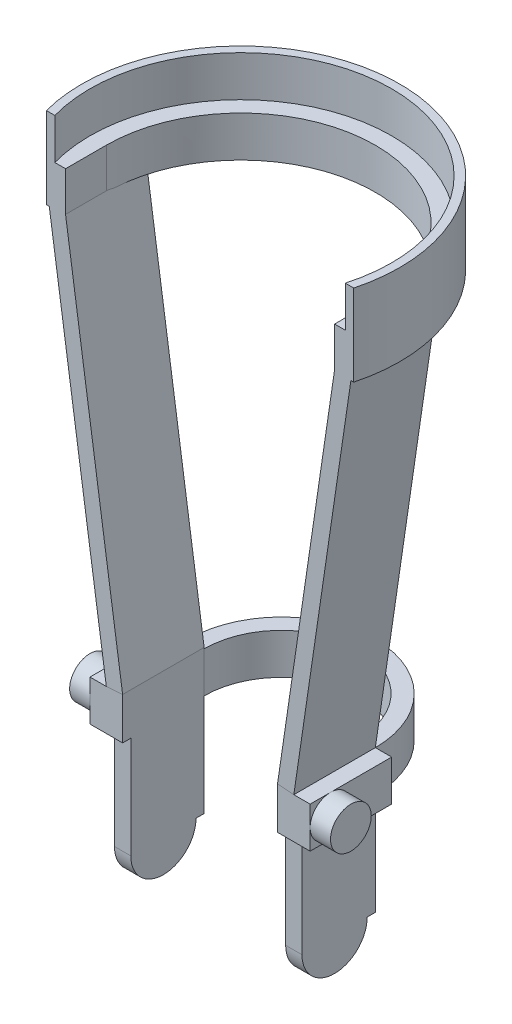
from build123d import *

# Parameters (mm, degrees)
EXTRUDE_4_DEPTH     = 10
EXTRUDE_8_DEPTH     = 20
SKETCH_16_W         = 8
SKETCH_16_H         = 40
SKETCH_19_W         = 8
SKETCH_19_H         = 40
SKETCH_21_R         = 16
EXTRUDE_13_DEPTH    = 8
SKETCH_22_R         = 16
EXTRUDE_14_DEPTH    = 8
SKETCH_23_W         = 7.590296008
SKETCH_23_H         = 50
CUT_EXTRUDE_2_DEPTH = 314.490031739
EXTRUDE_15_DEPTH    = 40
SKETCH_29_W         = 8
SKETCH_29_H         = 20
EXTRUDE_19_DEPTH    = 40
SKETCH_33_R         = 10
EXTRUDE_22_DEPTH    = 10
SKETCH_34_R         = 10
EXTRUDE_23_DEPTH    = 10


with BuildPart() as part:
    # Sketch 3D_1 → 凸台-拉伸4 (new, symmetric)
    with BuildSketch(Plane(origin=(-74, 270, 0), x_dir=(0.9909924304103234, 0, 0.13391789600139506), z_dir=(0, -1, 0))):
        with BuildLine():
            Line((0, 0), (2.67835792, 19.819848608))
            Line((2.67835792, 19.819848608), (10.606297363, 18.74850544))
            Line((10.606297363, 18.74850544), (7.927939443, -1.071343168))
            ThreePointArc((7.927939443, -1.071343168), (64.494858714, -75.315424711), (138.738940257, -18.74850544))
            Line((138.738940257, -18.74850544), (141.417298177, 1.071343168))
            Line((141.417298177, 1.071343168), (149.345237621, 0))
            Line((149.345237621, 0), (146.666879701, -19.819848608))
            ThreePointArc((146.666879701, -19.819848608), (63.423515546, -83.243364154), (0, 0))
        make_face()
    extrude(amount=EXTRUDE_4_DEPTH, both=True)



with BuildPart() as body_2:
    # Sketch 3D_2 → 凸台-拉伸8 (new body)
    with BuildSketch(Plane(origin=(-46, 50, 0), x_dir=(0.9771763639228009, 0, 0.2124296443310437), z_dir=(0, 1, 0))):
        with BuildLine():
            Line((0, 0), (4.248592887, -19.543527278))
            Line((4.248592887, -19.543527278), (12.066003798, -17.844090124))
            Line((12.066003798, -17.844090124), (7.817410911, 1.699437155))
            Line((7.817410911, 1.699437155), (3.568818025, 21.242964433))
            ThreePointArc((3.568818025, 21.242964433), (32.629193369, 66.447992747), (77.834221683, 37.387617402))
            Line((77.834221683, 37.387617402), (82.08281457, 17.844090124))
            Line((82.08281457, 17.844090124), (86.331407456, -1.699437155))
            Line((86.331407456, -1.699437155), (94.148818368, 0))
            Line((94.148818368, 0), (89.900225481, 19.543527278))
            Line((89.900225481, 19.543527278), (85.651632594, 39.087054557))
            ThreePointArc((85.651632594, 39.087054557), (30.929756215, 74.265403658), (-4.248592887, 19.543527278))
            Line((-4.248592887, 19.543527278), (0, 0))
        make_face()
    extrude(amount=EXTRUDE_8_DEPTH)


with BuildPart() as part_1:
    add(part.part)

    add(body_2.part)  # 扫描5 merges body 2
    # 扫描5: sweep along a path in 草图18
    with BuildLine(Plane.XY.offset(20)) as sweep_5_path:
        Line((-46, 0), (-46, 50))
        Line((-46, 50), (-46, 70))
        Line((-46, 70), (-74, 260))
        Line((-74, 260), (-74, 280))
    # 草图16 → 扫描5 (sweep)
    with BuildSketch(Plane(origin=(0, 0, 0), x_dir=(1, 0, 0), z_dir=(0, 1, 0))):
        with Locations((-42, 0)):
            Rectangle(SKETCH_16_W, SKETCH_16_H)
    sweep(path=sweep_5_path.line, transition=Transition.RIGHT)

    # 扫描6: sweep along a path in 草图20
    with BuildLine(Plane.XY.offset(20)) as sweep_6_path:
        Line((46, 0), (46, 50))
        Line((46, 50), (46, 70))
        Line((46, 70), (74, 260))
        Line((74, 260), (74, 280))
    # 草图19 → 扫描6 (sweep)
    with BuildSketch(Plane(origin=(0, 0, 0), x_dir=(1, 0, 0), z_dir=(0, 1, 0))):
        with Locations((42, 0)):
            Rectangle(SKETCH_19_W, SKETCH_19_H)
    sweep(path=sweep_6_path.line, transition=Transition.RIGHT)

    # 草图21 → 凸台-拉伸13 (add)
    with BuildSketch(Plane(origin=(46, 0, 0), x_dir=(0, 0, -1), z_dir=(1, 0, 0))):
        Circle(SKETCH_21_R)
    extrude(amount=-EXTRUDE_13_DEPTH)

    # 草图22 → 凸台-拉伸14 (add)
    with BuildSketch(Plane.ZY.offset(46)):
        Circle(SKETCH_22_R)
    extrude(amount=-EXTRUDE_14_DEPTH)

    # 草图23 → 切除-拉伸2 (cut, through all)
    with BuildSketch(Plane.ZY.offset(46)):
        with Locations((19.795148004, 25)):
            Rectangle(SKETCH_23_W, SKETCH_23_H)
    extrude(amount=-CUT_EXTRUDE_2_DEPTH, mode=Mode.SUBTRACT)

    # 草图25 → 凸台-拉伸15 (add)
    with BuildSketch(Plane.XZ.offset(-260)):
        with BuildLine():
            Line((71.246052522, 20), (75.3923073, 20))
            ThreePointArc((75.3923073, 20), (0, -78), (-75.3923073, 20))
            Line((-75.3923073, 20), (-71.246052522, 20))
            ThreePointArc((-71.246052522, 20), (0, -74), (71.246052522, 20))
        make_face()
    extrude(amount=-EXTRUDE_15_DEPTH)

    # 草图29 → 凸台-拉伸19 (add)
    with BuildSketch(Plane.XY.offset(20)):
        with Locations((-50, 60)):
            Rectangle(SKETCH_29_W, SKETCH_29_H)
        with Locations((50, 60)):
            Rectangle(SKETCH_29_W, SKETCH_29_H)
    extrude(amount=-EXTRUDE_19_DEPTH)

    # 草图33 → 凸台-拉伸22 (add)
    with BuildSketch(Plane.ZY.offset(54)):
        with Locations((10, 60)):
            Circle(SKETCH_33_R)
    extrude(amount=EXTRUDE_22_DEPTH)

    # 草图34 → 凸台-拉伸23 (add)
    with BuildSketch(Plane(origin=(54, 0, 0), x_dir=(0, 0, -1), z_dir=(1, 0, 0))):
        with Locations(Location((-10, 60, 0), (0, 0, 180))):
            Circle(SKETCH_34_R)
    extrude(amount=EXTRUDE_23_DEPTH)


solid = part_1.part
